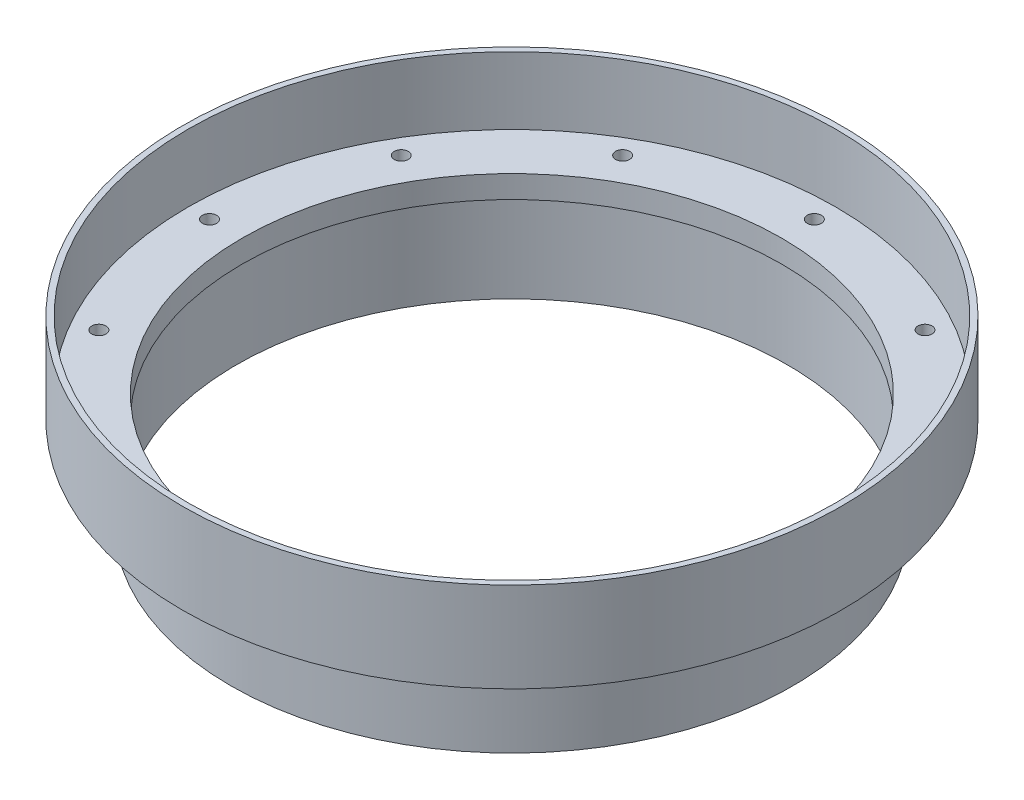
from build123d import *

# Parameters (mm, degrees)
SCREW_HOLES_COUNT = 12


with BuildPart() as part:
    # Cross Section → Main (revolve)
    with BuildSketch(Plane.XY):
        Polygon((-38.1, 0), (-38.1, -3.175), (-38.8874, -3.175), (-38.8874, -15.875), (-39.68115, -15.875), (-39.68115, -3.175), (-46.53915, -3.175), (-46.53915, 9.525), (-45.72, 9.525), (-45.72, 0), align=None)
    revolve(axis=Axis((0, 55, 0), (0, -1, 0)))

    # Sketch7 → #3-48 Tapped Hole1 (revolve, cut)
    with BuildSketch(Plane(origin=(-42.700575, 0, 0), x_dir=(0, 0, 1), z_dir=(1, 0, 0))):
        Polygon((0, 0), (0, 3.901027994), (0.99695, 3.302), (0.99695, 0), align=None)
    f_3_48_tapped_hole1 = revolve(axis=Axis((-42.700575, 6.35, 0), (0, -1, 0)), mode=Mode.SUBTRACT)

    # Screw Holes: #3-48 Tapped Hole1 ×12 about axis
    screw_holes_axis = Axis((0, 0, 0), (0, 1, 0))
    for i in range(1, SCREW_HOLES_COUNT):
        add(f_3_48_tapped_hole1.rotate(screw_holes_axis, i * 360 / SCREW_HOLES_COUNT), mode=Mode.SUBTRACT)


solid = part.part
